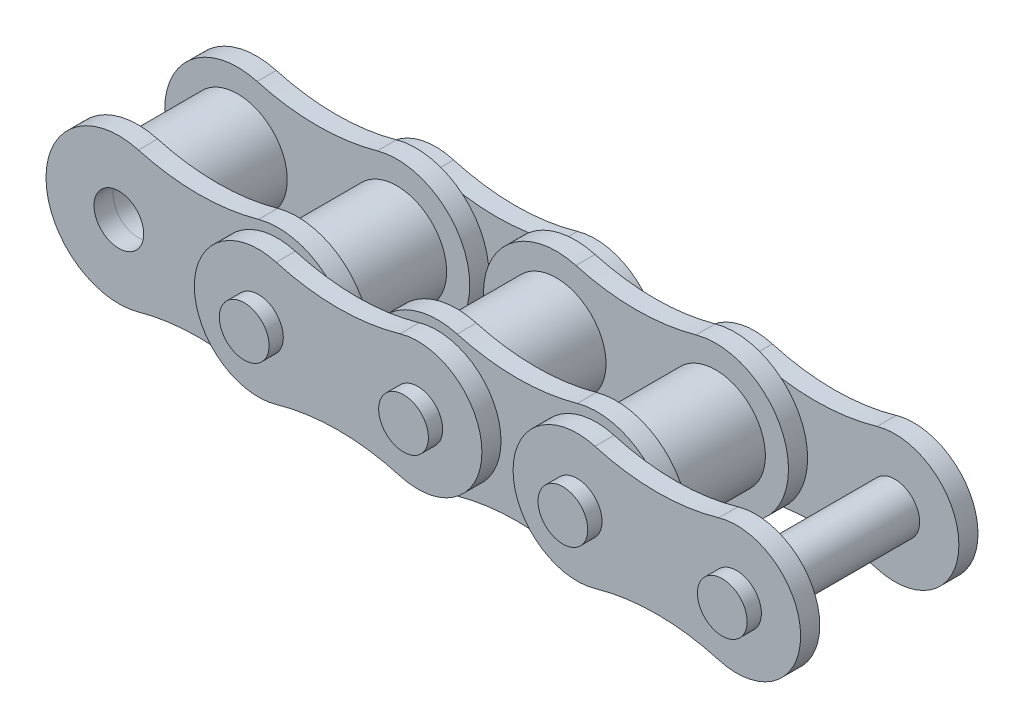
from build123d import *

# Parameters (mm, degrees)
SKETCH4_R                  = 3.9624
SKETCH4_R_2                = 2.0066
BOSS_EXTRUDE1_DEPTH        = 3.96875
BOSS_EXTRUDE1_2_DEPTH      = 3.96875
SKETCH5_R                  = 1.9812
BOSS_EXTRUDE2_DEPTH        = 1.524
LPATTERN1_COUNT            = 2
LPATTERN1_PITCH            = 12.7
SKETCH7_R                  = 1.9812
BOSS_EXTRUDE3_DEPTH        = 1.524
SKETCH8_R                  = 1.9812
BOSS_EXTRUDE4_DEPTH        = 8.2042
BOSS_EXTRUDE4_DEPTH_BACK   = 8.2042
BOSS_EXTRUDE4_2_DEPTH      = 8.2042
BOSS_EXTRUDE4_2_DEPTH_BACK = 8.2042
LPATTERN2_COUNT            = 2
LPATTERN2_PITCH            = 25.4


with BuildPart() as part:
    # Sketch4 → Boss-Extrude1 (new body, symmetric)
    with BuildSketch(Plane.XY):
        with Locations((-6.35, 0)):
            Circle(SKETCH4_R)
        with Locations((-6.35, 0)):
            Circle(SKETCH4_R_2, mode=Mode.SUBTRACT)
    extrude(amount=BOSS_EXTRUDE1_DEPTH, both=True)


with BuildPart() as body_2:
    # Sketch4 → Boss-Extrude1 2 (new body, symmetric)
    with BuildSketch(Plane.XY):
        with Locations((6.35, 0)):
            Circle(SKETCH4_R)
        with Locations((6.35, 0)):
            Circle(SKETCH4_R_2, mode=Mode.SUBTRACT)
    extrude(amount=BOSS_EXTRUDE1_2_DEPTH, both=True)


with BuildPart() as body_3:
    # Sketch5 → Boss-Extrude2 (new body)
    with BuildSketch(Plane.XY.offset(3.96875)):
        with BuildLine():
            ThreePointArc((-4.787931893, 5.589740462), (-12.1539, 0), (-4.787931893, -5.589740462))
            ThreePointArc((-4.787931893, -5.589740462), (0, -4.933315), (4.787931893, -5.589740462))
            ThreePointArc((4.787931893, -5.589740462), (12.1539, 0), (4.787931893, 5.589740462))
            ThreePointArc((4.787931893, 5.589740462), (0, 4.933315), (-4.787931893, 5.589740462))
        make_face()
        with Locations((-6.35, 0)):
            Circle(SKETCH5_R, mode=Mode.SUBTRACT)
        with Locations((6.35, 0)):
            Circle(SKETCH5_R, mode=Mode.SUBTRACT)
    extrude(amount=BOSS_EXTRUDE2_DEPTH)


with BuildPart() as lpattern1_1:
    # LPattern1: pattern copy
    add(body_2.part.moved(Location(Vector(1, 0, 0) * (1 * LPATTERN1_PITCH))))


with BuildPart() as body_5:
    # Sketch7 → Boss-Extrude3 (new body)
    with BuildSketch(Plane.XY.offset(-5.54355)):
        with BuildLine():
            ThreePointArc((7.766432158, 4.907095024), (1.242568, 0), (7.766432158, -4.907095024))
            ThreePointArc((7.766432158, -4.907095024), (12.7, -4.209302295), (17.633567842, -4.907095024))
            ThreePointArc((17.633567842, -4.907095024), (24.157432, 0), (17.633567842, 4.907095024))
            ThreePointArc((17.633567842, 4.907095024), (12.7, 4.209302295), (7.766432158, 4.907095024))
        make_face()
        with Locations((6.35, 0)):
            Circle(SKETCH7_R, mode=Mode.SUBTRACT)
        with Locations((19.05, 0)):
            Circle(SKETCH7_R, mode=Mode.SUBTRACT)
    extrude(amount=-BOSS_EXTRUDE3_DEPTH)


with BuildPart() as body_6:
    # Mirror1: mirrored copy
    add(body_3.part.mirror(Plane.XY))


with BuildPart() as body_7:
    # Mirror1 2: mirrored copy
    add(body_5.part.mirror(Plane.XY))


with BuildPart() as body_8:
    # Sketch8 → Boss-Extrude4 (new body, two sides)
    with BuildSketch(Plane.XY) as boss_extrude4_sk:
        with Locations((6.35, 0)):
            Circle(SKETCH8_R)
    extrude(amount=BOSS_EXTRUDE4_DEPTH)
    extrude(boss_extrude4_sk.sketch, amount=-BOSS_EXTRUDE4_DEPTH_BACK)


with BuildPart() as body_9:
    # Sketch8 → Boss-Extrude4 2 (new body, two sides)
    with BuildSketch(Plane.XY) as boss_extrude4_2_sk:
        with Locations((19.05, 0)):
            Circle(SKETCH8_R)
    extrude(amount=BOSS_EXTRUDE4_2_DEPTH)
    extrude(boss_extrude4_2_sk.sketch, amount=-BOSS_EXTRUDE4_2_DEPTH_BACK)


with BuildPart() as lpattern2_1:
    # LPattern2: pattern copy
    add(body_9.part.moved(Location(Vector(1, 0, 0) * (1 * LPATTERN2_PITCH))))


with BuildPart() as lpattern2_2:
    # LPattern2: pattern copy
    add(body_8.part.moved(Location(Vector(1, 0, 0) * (1 * LPATTERN2_PITCH))))


with BuildPart() as lpattern2_3:
    # LPattern2: pattern copy
    add(body_7.part.moved(Location(Vector(1, 0, 0) * (1 * LPATTERN2_PITCH))))


with BuildPart() as lpattern2_4:
    # LPattern2: pattern copy
    add(body_6.part.moved(Location(Vector(1, 0, 0) * (1 * LPATTERN2_PITCH))))


with BuildPart() as lpattern2_5:
    # LPattern2: pattern copy
    add(body_5.part.moved(Location(Vector(1, 0, 0) * (1 * LPATTERN2_PITCH))))


with BuildPart() as lpattern2_6:
    # LPattern2: pattern copy
    add(lpattern1_1.part.moved(Location(Vector(1, 0, 0) * (1 * LPATTERN2_PITCH))))


with BuildPart() as lpattern2_7:
    # LPattern2: pattern copy
    add(body_3.part.moved(Location(Vector(1, 0, 0) * (1 * LPATTERN2_PITCH))))


with BuildPart() as lpattern2_8:
    # LPattern2: pattern copy
    add(body_2.part.moved(Location(Vector(1, 0, 0) * (1 * LPATTERN2_PITCH))))


with BuildPart() as lpattern2_9:
    # LPattern2: pattern copy
    add(part.part.moved(Location(Vector(1, 0, 0) * (1 * LPATTERN2_PITCH))))


with BuildPart() as body_2_1:
    add(body_2.part)

    # Combine1: union body 3, LPattern1_1, body 5, body 6, body 7, body 8, body 9, LPattern2_1, LPattern2_2, LPattern2_3, LPattern2_4, LPattern2_5, LPattern2_7, LPattern2_8, LPattern2_9, part
    add(body_3.part)
    add(lpattern1_1.part)
    add(body_5.part)
    add(body_6.part)
    add(body_7.part)
    add(body_8.part)
    add(body_9.part)
    add(lpattern2_1.part)
    add(lpattern2_2.part)
    add(lpattern2_3.part)
    add(lpattern2_4.part)
    add(lpattern2_5.part)
    add(lpattern2_7.part)
    add(lpattern2_8.part)
    add(lpattern2_9.part)
    add(part.part)


solid = body_2_1.part
